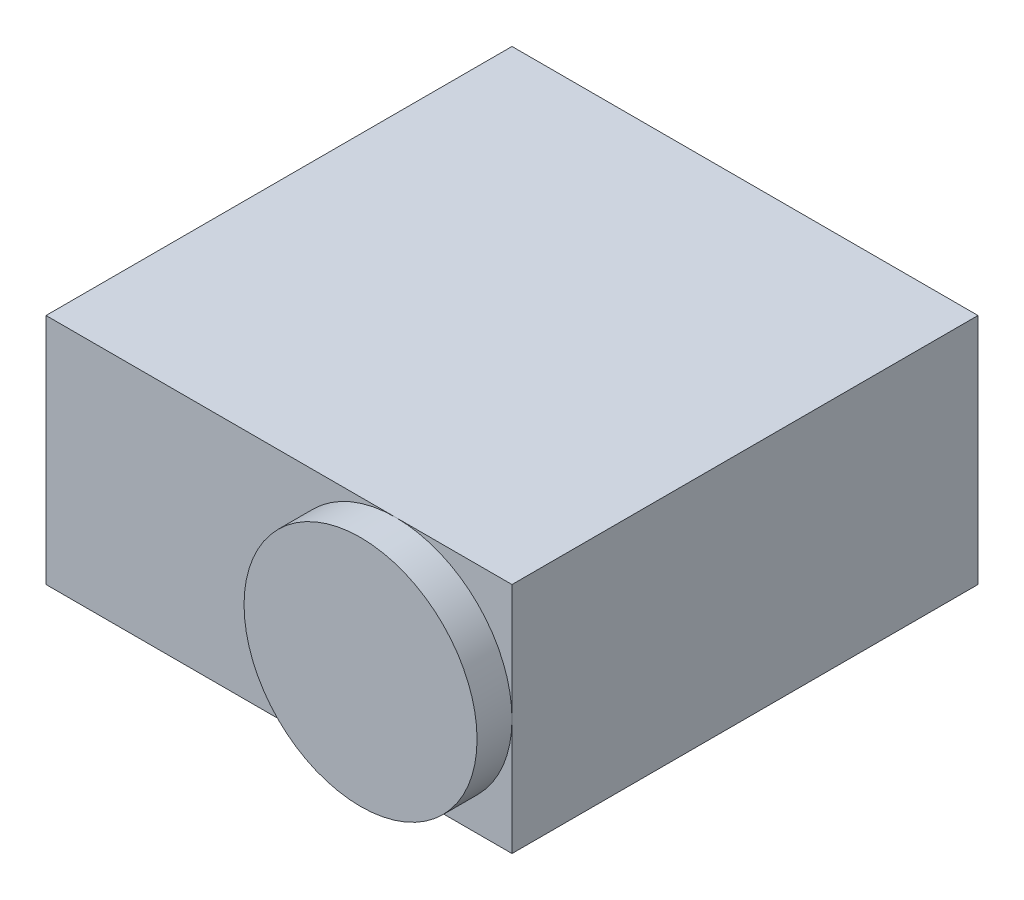
from build123d import *

# Parameters (mm, degrees)
SKETCH1_W           = 40
SKETCH1_H           = 40
BOSS_EXTRUDE1_DEPTH = 20
SKETCH3_R           = 10
BOSS_EXTRUDE2_DEPTH = 3


with BuildPart() as part:
    # Sketch1 → Boss-Extrude1 (new body)
    with BuildSketch(Plane(origin=(0, 0, 0), x_dir=(1, 0, 0), z_dir=(0, 1, 0))):
        with Locations((20, 20)):
            Rectangle(SKETCH1_W, SKETCH1_H)
    extrude(amount=BOSS_EXTRUDE1_DEPTH)

    # Sketch3 → Boss-Extrude2 (add)
    with BuildSketch(Plane.XY):
        with Locations((30, 10)):
            Circle(SKETCH3_R)
    extrude(amount=BOSS_EXTRUDE2_DEPTH)


solid = part.part
